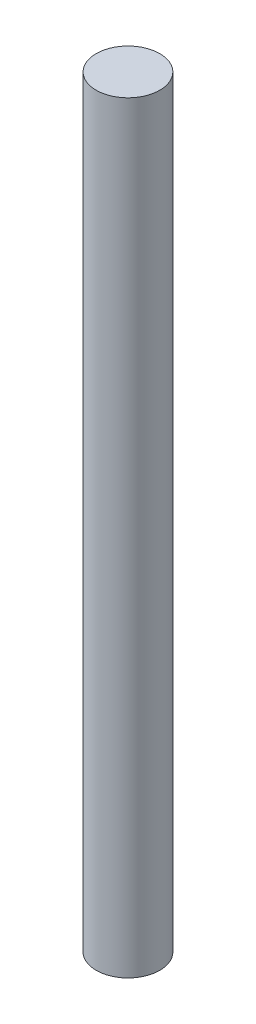
from build123d import *

# Parameters (mm, degrees)
SKETCH1_W = 1.5875
SKETCH1_H = 38.1


with BuildPart() as part:
    # Sketch1 → Revolve1 (revolve)
    with BuildSketch(Plane.XY):
        with Locations((-0.79375, 19.05)):
            Rectangle(SKETCH1_W, SKETCH1_H)
    revolve(axis=Axis((0, 38.1, 0), (0, -1, 0)))


solid = part.part
